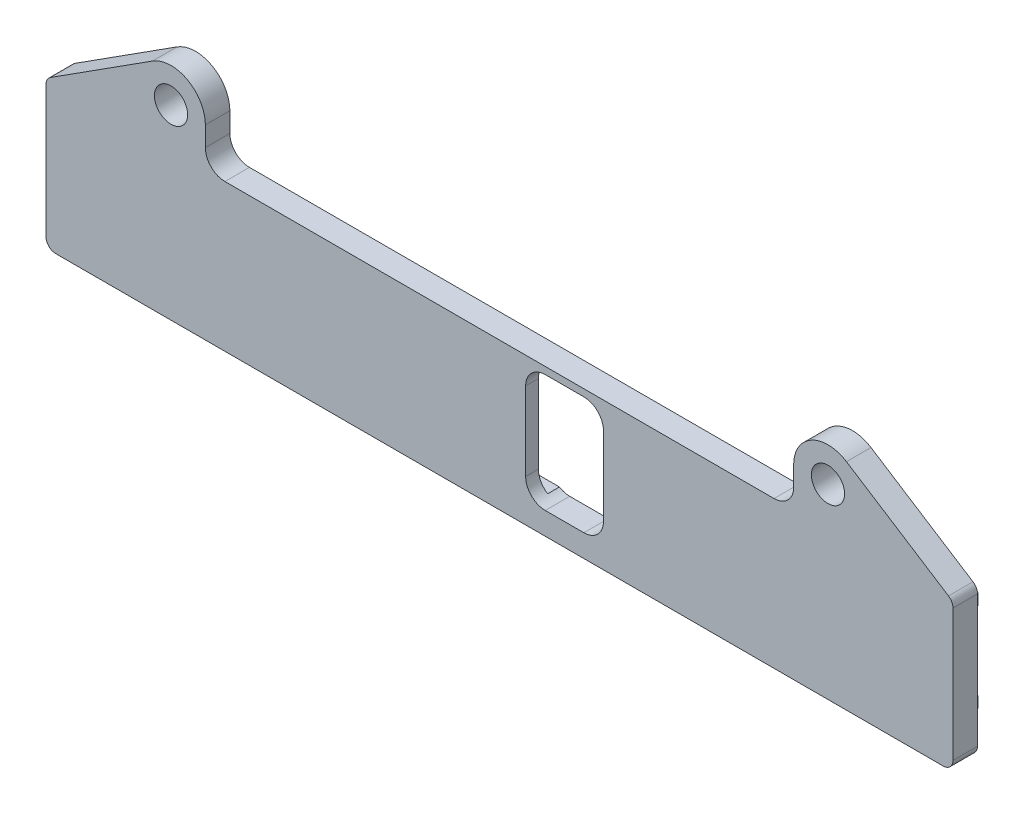
from build123d import *

# Parameters (mm, degrees)
BOSS_EXTRUDE1_DEPTH   = 3.175
F_6_CLEARANCE_HOLE1_D = 4.3053
FILLET3_R             = 1.27
SKETCH4_W             = 10.08
SKETCH4_H             = 15.24
CUT_EXTRUDE1_DEPTH    = 4.175
FILLET4_R             = 2.54
CUT_EXTRUDE2_DEPTH    = 1.524
BOSS_EXTRUDE2_DEPTH   = 1.524


with BuildPart() as part:
    # Sketch1 → Boss-Extrude1 (new body)
    with BuildSketch(Plane.XY):
        with BuildLine():
            Line((58.7375, -67.1354797), (58.7375, -48.0854797))
            Line((58.7375, -48.0854797), (44.939976119, -39.26086832))
            ThreePointArc((44.939976119, -39.26086832), (40.410479427, -39.106525106), (38.1, -43.0054797))
            Line((38.1, -43.0054797), (38.1, -45.5454797))
            ThreePointArc((38.1, -45.5454797), (37.356051224, -47.341530924), (35.56, -48.0854797))
            Line((35.56, -48.0854797), (-35.56, -48.0854797))
            ThreePointArc((-35.56, -48.0854797), (-37.356051224, -47.341530924), (-38.1, -45.5454797))
            Line((-38.1, -45.5454797), (-38.1, -43.0054797))
            ThreePointArc((-38.1, -43.0054797), (-40.410479427, -39.106525106), (-44.939976119, -39.26086832))
            Line((-44.939976119, -39.26086832), (-58.7375, -48.0854797))
            Line((-58.7375, -48.0854797), (-58.7375, -67.1354797))
            Line((-58.7375, -67.1354797), (58.7375, -67.1354797))
        make_face()
    extrude(amount=BOSS_EXTRUDE1_DEPTH)

    # #6 Clearance Hole1 (through all)
    with Locations(Plane(origin=(0, 0, 0), x_dir=(-1, 0, 0), z_dir=(0, 0, -1))):
        with Locations((42.545, -43.0054797), (-42.545, -43.0054797)):
            Hole(F_6_CLEARANCE_HOLE1_D / 2)

    # Fillet3
    fillet3_edges = [part.edges().sort_by_distance(p)[0] for p in [
        (-58.7375, -67.1354797, 1.5875),
        (-58.7375, -48.0854797, 1.5875),
        (58.7375, -48.0854797, 1.5875),
        (58.7375, -67.1354797, 1.5875),
    ]]
    fillet(fillet3_edges, radius=FILLET3_R)

    # Sketch4 → Cut-Extrude1 (cut, through all)
    with BuildSketch(Plane.XY.offset(3.175)):
        with Locations((8.426666963, -56.6198797)):
            Rectangle(SKETCH4_W, SKETCH4_H)
    extrude(amount=-CUT_EXTRUDE1_DEPTH, mode=Mode.SUBTRACT)

    # Fillet4
    fillet4_edges = [part.edges().sort_by_distance(p)[0] for p in [
        (3.386666963, -64.2398797, 1.5875),
        (3.386666963, -48.9998797, 1.5875),
        (13.466666963, -48.9998797, 1.5875),
        (13.466666963, -64.2398797, 1.5875),
    ]]
    fillet(fillet4_edges, radius=FILLET4_R)

    # Sketch7 → Cut-Extrude2 (cut)
    with BuildSketch(Plane(origin=(0, 0, 0), x_dir=(-1, 0, 0), z_dir=(0, 0, -1))):
        Polygon((58.039, -60.872510434), (58.039, -52.367248965), (55.052630735, -49.3808797), (-55.052631243, -49.3808797), (-58.039000508, -52.367248965), (-58.039000508, -60.872510434), (-55.052631243, -63.8588797), (55.052630735, -63.8588797), align=None)
    extrude(amount=-CUT_EXTRUDE2_DEPTH, mode=Mode.SUBTRACT)

    # Sketch5 → Boss-Extrude2 (add)
    with BuildSketch(Plane(origin=(0, 0, 0), x_dir=(-1, 0, 0), z_dir=(0, 0, -1))):
        Polygon((-55.814631243, -50.1428797), (-57.277000508, -50.1428797), (-57.277000508, -51.605248965), align=None)
        Polygon((-55.814631243, -63.0968797), (-57.277000508, -63.0968797), (-57.277000508, -61.634510434), align=None)
        Polygon((57.277, -61.634510434), (57.277, -63.0968797), (55.814630735, -63.0968797), align=None)
        Polygon((55.814630735, -50.1428797), (57.277, -50.1428797), (57.277, -51.605248965), align=None)
    extrude(amount=BOSS_EXTRUDE2_DEPTH)


solid = part.part
